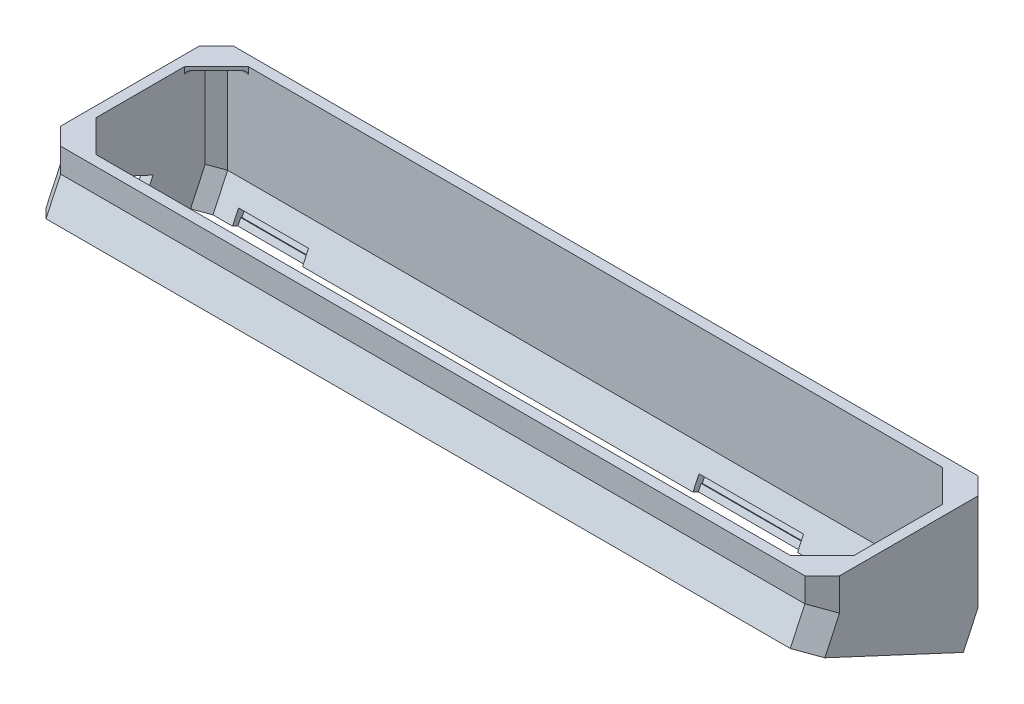
from build123d import *

# Parameters (mm, degrees)
SALIENTE_EXTRUIR2_DEPTH = 3
SALIENTE_EXTRUIR3_DEPTH = 7
CORTAR_EXTRUIR1_DEPTH   = 19
CROQUIS5_W              = 231.218781219
CROQUIS5_H              = 62.937062938
CORTAR_EXTRUIR2_DEPTH   = 3
SALIENTE_EXTRUIR4_DEPTH = 35
SALIENTE_EXTRUIR5_DEPTH = 1
REDONDEO4_R             = 1
CORTAR_EXTRUIR3_DEPTH   = 237
SALIENTE_EXTRUIR6_DEPTH = 10
CORTAR_EXTRUIR4_DEPTH   = 10
CROQUIS14_W             = 20.2
CROQUIS14_H             = 4.1
CROQUIS14_W_2           = 30.2
CORTAR_EXTRUIR5_DEPTH   = 2.1
CROQUIS15_W             = 30.2
CROQUIS15_H             = 4.1
CROQUIS15_W_2           = 20.2
CORTAR_EXTRUIR6_DEPTH   = 2.1
CROQUIS16_W             = 20.2
CROQUIS16_H             = 1.9
CROQUIS16_W_2           = 30.2
SALIENTE_EXTRUIR7_DEPTH = 0.4
CROQUIS17_W             = 30.2
CROQUIS17_H             = 1.9
CROQUIS17_W_2           = 20.2
SALIENTE_EXTRUIR8_DEPTH = 0.4
CORTAR_EXTRUIR7_DEPTH   = 2.1
SALIENTE_EXTRUIR9_DEPTH = 0.4
CORTAR_EXTRUIR8_DEPTH   = 10


with BuildPart() as part:
    # Croquis2 → Saliente-Extruir2 (new body)
    with BuildSketch(Plane(origin=(0, 0, 0), x_dir=(1, 0, 0), z_dir=(0, 1, 0))):
        Polygon((-128.963414634, 73.976399667), (-123.963414634, 78.976399667), (91.036585366, 78.976399667), (96.036585366, 73.976399667), (96.036585366, 33.976399667), (91.036585366, 28.976399667), (-123.963414634, 28.976399667), (-128.963414634, 33.976399667), align=None)
    extrude(amount=SALIENTE_EXTRUIR2_DEPTH)

    # Croquis3 → Saliente-Extruir3 (add)
    with BuildSketch(Plane(origin=(0, 3, 0), x_dir=(1, 0, 0), z_dir=(0, 1, 0))):
        Polygon((-123.963414634, 78.976399667), (-128.963414634, 73.976399667), (-128.963414634, 33.976399667), (-123.963414634, 28.976399667), (91.036585366, 28.976399667), (96.036585366, 33.976399667), (96.036585366, 73.976399667), (91.036585366, 78.976399667), align=None)
        Polygon((90.208158241, 76.976399667), (-123.134987509, 76.976399667), (-126.963414634, 73.147972543), (-126.963414634, 34.804826792), (-123.134987509, 30.976399667), (90.208158241, 30.976399667), (94.036585366, 34.804826792), (94.036585366, 73.147972543), align=None, mode=Mode.SUBTRACT)
    extrude(amount=SALIENTE_EXTRUIR3_DEPTH)

    # Croquis4 → Cortar-Extruir1 (cut)
    with BuildSketch(Plane.XZ):
        with BuildLine():
            ThreePointArc((-103.963414634, -47.176399667), (-106.438288368, -48.201525933), (-107.463414634, -50.676399667))
            Line((-107.463414634, -50.676399667), (-103.963414634, -50.676399667))
            Line((-103.963414634, -50.676399667), (-103.963414634, -47.176399667))
        make_face()
        with BuildLine():
            Line((-103.963414634, -50.676399667), (-107.463414634, -50.676399667))
            ThreePointArc((-107.463414634, -50.676399667), (-106.438288368, -53.151273402), (-103.963414634, -54.176399667))
            Line((-103.963414634, -54.176399667), (-103.963414634, -50.676399667))
        make_face()
        with BuildLine():
            Line((-103.963414634, -47.176399667), (-103.963414634, -50.676399667))
            Line((-103.963414634, -50.676399667), (-100.463414634, -50.676399667))
            ThreePointArc((-100.463414634, -50.676399667), (-101.4885409, -48.201525933), (-103.963414634, -47.176399667))
        make_face()
        with BuildLine():
            Line((-100.463414634, -50.676399667), (-103.963414634, -50.676399667))
            Line((-103.963414634, -50.676399667), (-103.963414634, -54.176399667))
            ThreePointArc((-103.963414634, -54.176399667), (-101.4885409, -53.151273402), (-100.463414634, -50.676399667))
        make_face()
    extrude(amount=-CORTAR_EXTRUIR1_DEPTH, mode=Mode.SUBTRACT)

    # Croquis5 → Cortar-Extruir2 (cut)
    with BuildSketch(Plane.XZ):
        with Locations((-15.039838211, -54.605736692)):
            Rectangle(CROQUIS5_W, CROQUIS5_H)
    extrude(amount=-CORTAR_EXTRUIR2_DEPTH, mode=Mode.SUBTRACT)

    # Croquis6 → Saliente-Extruir4 (add)
    with BuildSketch(Plane(origin=(0, 10, 0), x_dir=(1, 0, 0), z_dir=(0, 1, 0))):
        Polygon((-128.963414634, 33.976399667), (-123.963414634, 28.976399667), (91.036585366, 28.976399667), (96.036585366, 33.976399667), (96.036585366, 73.976399667), (91.036585366, 78.976399667), (-123.963414634, 78.976399667), (-128.963414634, 73.976399667), align=None)
        Polygon((93.036585366, 35.219040355), (89.793944679, 31.976399667), (-122.720773947, 31.976399667), (-125.963414634, 35.219040355), (-125.963414634, 72.73375898), (-122.720773947, 75.976399667), (89.793944679, 75.976399667), (93.036585366, 72.73375898), align=None, mode=Mode.SUBTRACT)
    extrude(amount=-SALIENTE_EXTRUIR4_DEPTH)

    # Croquis7 → Saliente-Extruir5 (add)
    with BuildSketch(Plane(origin=(0, 10, 0), x_dir=(1, 0, 0), z_dir=(0, 1, 0))):
        Polygon((-125.963414634, 66.73375898), (-116.720773947, 75.976399667), (-122.720773947, 75.976399667), (-125.963414634, 72.73375898), align=None)
        Polygon((-125.963414634, 41.219040355), (-116.720773947, 31.976399667), (-122.720773947, 31.976399667), (-125.963414634, 35.219040355), align=None)
        Polygon((93.036585366, 41.219040355), (83.793944679, 31.976399667), (89.793944679, 31.976399667), (93.036585366, 35.219040355), align=None)
        Polygon((83.793944679, 75.976399667), (93.036585366, 66.73375898), (93.036585366, 72.73375898), (89.793944679, 75.976399667), align=None)
    extrude(amount=-SALIENTE_EXTRUIR5_DEPTH)

    # Redondeo4
    redondeo4_edges = [part.edges().sort_by_distance(p)[0] for p in [
        (-125.963414634, 9, -69.73375898),
        (-124.342094291, 9, -74.355079324),
        (-119.720773947, 9, -75.976399667),
        (-125.963414634, 9, -38.219040355),
        (-119.720773947, 9, -31.976399667),
        (-124.342094291, 9, -33.597720011),
        (93.036585366, 9, -38.219040355),
        (91.415265022, 9, -33.597720011),
        (86.793944679, 9, -31.976399667),
        (86.793944679, 9, -75.976399667),
        (91.415265022, 9, -74.355079324),
        (93.036585366, 9, -69.73375898),
    ]]
    fillet(redondeo4_edges, radius=REDONDEO4_R)

    # Croquis8 → Cortar-Extruir3 (cut)
    with BuildSketch(Plane.ZY.offset(128.963414634)):
        Polygon((-73.976399667, -25), (-73.976399667, -17.983844617), (-78.976399667, -20.315382908), (-78.976399667, -25), align=None)
        Polygon((-33.976399667, -25), (-33.976399667, 0.668461709), (-73.976399667, -17.983844617), (-73.976399667, -25), align=None)
        Polygon((-28.976399667, -25), (-28.976399667, 3), (-33.976399667, 0.668461709), (-33.976399667, -25), align=None)
    extrude(amount=-CORTAR_EXTRUIR3_DEPTH, mode=Mode.SUBTRACT)

    # Croquis9 → Saliente-Extruir6 (add)
    with BuildSketch(Plane(origin=(0, 13.562786388, -6.324431159), x_dir=(1, 0, 0), z_dir=(0, -0.906307787, 0.422618262))):
        Polygon((-128.963414634, -30.510571468), (-123.963414634, -24.993681874), (91.036585366, -24.993681874), (96.036585366, -30.510571468), (96.036585366, -74.645688227), (91.036585366, -80.162577822), (-123.963414634, -80.162577822), (-128.963414634, -74.645688227), align=None)
        Polygon((-125.963414634, -31.881673764), (-125.963414634, -73.274585932), (-122.720773947, -76.852444065), (89.793944679, -76.852444065), (93.036585366, -73.274585932), (93.036585366, -31.881673764), (89.793944679, -28.303815631), (-122.720773947, -28.303815631), align=None, mode=Mode.SUBTRACT)
    extrude(amount=SALIENTE_EXTRUIR6_DEPTH)

    # Croquis13 → Cortar-Extruir4 (cut)
    with BuildSketch(Plane.ZY.offset(128.963414634)):
        Polygon((-52.034030749, -12.823115041), (-50.595453573, -15.90815375), (-46.970222425, -14.217680703), (-48.408799601, -11.132641994), align=None)
        Polygon((-55.659261897, -14.513588088), (-54.220684722, -17.598626797), (-50.595453573, -15.90815375), (-52.034030749, -12.823115041), align=None)
    extrude(amount=-CORTAR_EXTRUIR4_DEPTH, mode=Mode.SUBTRACT)

    # Croquis14 → Cortar-Extruir5 (cut)
    with BuildSketch(Plane(origin=(0, -32.479246321, -69.651968509), x_dir=(1, 0, 0), z_dir=(0, 0.422618262, 0.906307787))):
        with Locations((-106.963414634, 7.01487902)):
            Rectangle(CROQUIS14_W, CROQUIS14_H)
        with Locations((31.036585366, 7.01487902)):
            Rectangle(CROQUIS14_W_2, CROQUIS14_H)
    extrude(amount=-CORTAR_EXTRUIR5_DEPTH, mode=Mode.SUBTRACT)

    # Croquis15 → Cortar-Extruir6 (cut)
    with BuildSketch(Plane(origin=(0, -11.961709362, -25.651968509), x_dir=(-1, 0, 0), z_dir=(0, -0.422618262, -0.906307787))):
        with Locations((-31.036585366, 7.01487902)):
            Rectangle(CROQUIS15_W, CROQUIS15_H)
        with Locations((106.963414634, 7.01487902)):
            Rectangle(CROQUIS15_W_2, CROQUIS15_H)
    extrude(amount=-CORTAR_EXTRUIR6_DEPTH, mode=Mode.SUBTRACT)

    # Croquis16 → Saliente-Extruir7 (add)
    with BuildSketch(Plane(origin=(0, -11.074211013, -23.748722156), x_dir=(-1, 0, 0), z_dir=(0, -0.422618262, -0.906307787))):
        with Locations((106.963414634, 5.91487902)):
            Rectangle(CROQUIS16_W, CROQUIS16_H)
        with Locations((-31.036585366, 5.91487902)):
            Rectangle(CROQUIS16_W_2, CROQUIS16_H)
    extrude(amount=SALIENTE_EXTRUIR7_DEPTH)

    # Croquis17 → Saliente-Extruir8 (add)
    with BuildSketch(Plane(origin=(0, -33.366744671, -71.555214862), x_dir=(1, 0, 0), z_dir=(0, 0.422618262, 0.906307787))):
        with Locations((31.036585366, 5.91487902)):
            Rectangle(CROQUIS17_W, CROQUIS17_H)
        with Locations((-106.963414634, 5.91487902)):
            Rectangle(CROQUIS17_W_2, CROQUIS17_H)
    extrude(amount=SALIENTE_EXTRUIR8_DEPTH)

    # Croquis18 → Cortar-Extruir7 (cut)
    with BuildSketch(Plane.ZY.offset(-93.036585366)):
        Polygon((-58.899894466, -21.987333973), (-60.632629339, -18.271472046), (-42.325212041, -9.734583159), (-40.592477167, -13.450445086), align=None)
    extrude(amount=-CORTAR_EXTRUIR7_DEPTH, mode=Mode.SUBTRACT)

    # Croquis19 → Saliente-Extruir9 (add)
    with BuildSketch(Plane.ZY.offset(-95.136585366)):
        Polygon((-58.899894466, -21.987333973), (-59.702869163, -20.265349177), (-41.395451865, -11.72846029), (-40.592477167, -13.450445086), align=None)
    extrude(amount=SALIENTE_EXTRUIR9_DEPTH)

    # Croquis20 → Cortar-Extruir8 (cut)
    with BuildSketch(Plane.ZY.offset(128.963414634)):
        Polygon((-48.599624209, -8.357215719), (-53.131163144, -10.470307028), (-52.034030749, -12.823115041), (-48.408799601, -11.132641994), (-46.970222425, -14.217680703), (-46.063914638, -13.795062441), align=None)
        Polygon((-57.662702079, -12.583398337), (-55.126992509, -18.021245059), (-54.220684722, -17.598626797), (-55.659261897, -14.513588088), (-52.034030749, -12.823115041), (-53.131163144, -10.470307028), align=None)
    extrude(amount=-CORTAR_EXTRUIR8_DEPTH, mode=Mode.SUBTRACT)


solid = part.part
